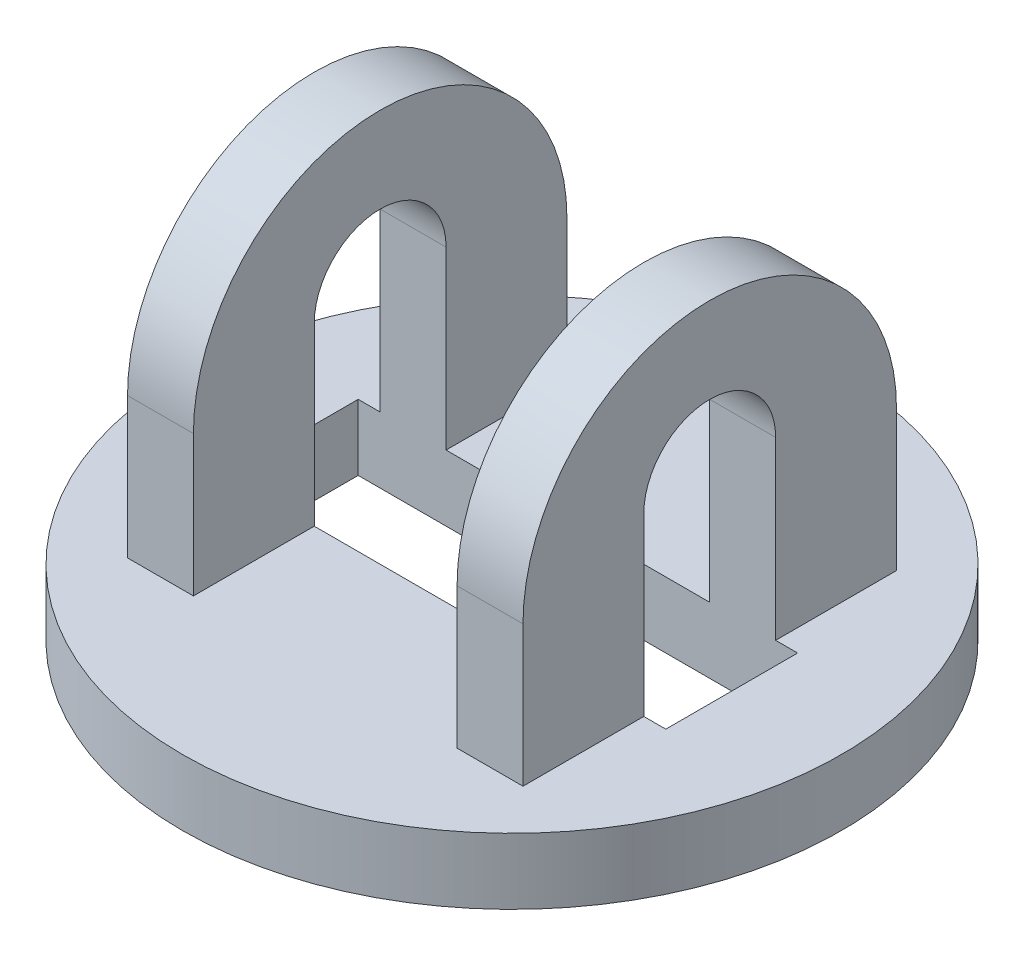
from build123d import *

# Parameters (mm, degrees)
SKETCH1_R           = 15
BOSS_EXTRUDE1_DEPTH = 3
SKETCH2_W           = 3
SKETCH2_H           = 17
BOSS_EXTRUDE2_DEPTH = 15
CUT_EXTRUDE1_DEPTH  = 25
SKETCH4_W           = 20
SKETCH4_H           = 6
CUT_EXTRUDE2_DEPTH  = 11
CUT_EXTRUDE3_DEPTH  = 25


with BuildPart() as part:
    # Sketch1 → Boss-Extrude1 (new body)
    with BuildSketch(Plane(origin=(0, 0, 0), x_dir=(1, 0, 0), z_dir=(0, 1, 0))):
        Circle(SKETCH1_R)
    extrude(amount=BOSS_EXTRUDE1_DEPTH)

    # Sketch2 → Boss-Extrude2 (add)
    with BuildSketch(Plane(origin=(0, 3, 0), x_dir=(1, 0, 0), z_dir=(0, 1, 0))):
        with Locations((-7.5, 0)):
            Rectangle(SKETCH2_W, SKETCH2_H)
        with Locations((7.5, 0)):
            Rectangle(SKETCH2_W, SKETCH2_H)
    extrude(amount=BOSS_EXTRUDE2_DEPTH)

    # Sketch3 → Cut-Extrude1 (cut, through all)
    with BuildSketch(Plane.ZY.offset(9)):
        with BuildLine():
            Line((-8.5, 9.4), (-8.5, 18))
            Line((-8.5, 18), (8.5, 18))
            Line((8.5, 18), (8.5, 9.4))
            ThreePointArc((8.5, 9.4), (0, 17.9), (-8.5, 9.4))
        make_face()
    extrude(amount=-CUT_EXTRUDE1_DEPTH, mode=Mode.SUBTRACT)

    # Sketch4 → Cut-Extrude2 (cut)
    with BuildSketch(Plane(origin=(0, 0, 0), x_dir=(-1, 0, 0), z_dir=(0, -1, 0))):
        Rectangle(SKETCH4_W, SKETCH4_H)
    extrude(amount=-CUT_EXTRUDE2_DEPTH, mode=Mode.SUBTRACT)

    # Sketch5 → Cut-Extrude3 (cut, through all)
    with BuildSketch(Plane.ZY.offset(9)):
        with BuildLine():
            Line((3, 11), (-3, 11))
            ThreePointArc((-3, 11), (0, 14), (3, 11))
        make_face()
    extrude(amount=-CUT_EXTRUDE3_DEPTH, mode=Mode.SUBTRACT)


solid = part.part
